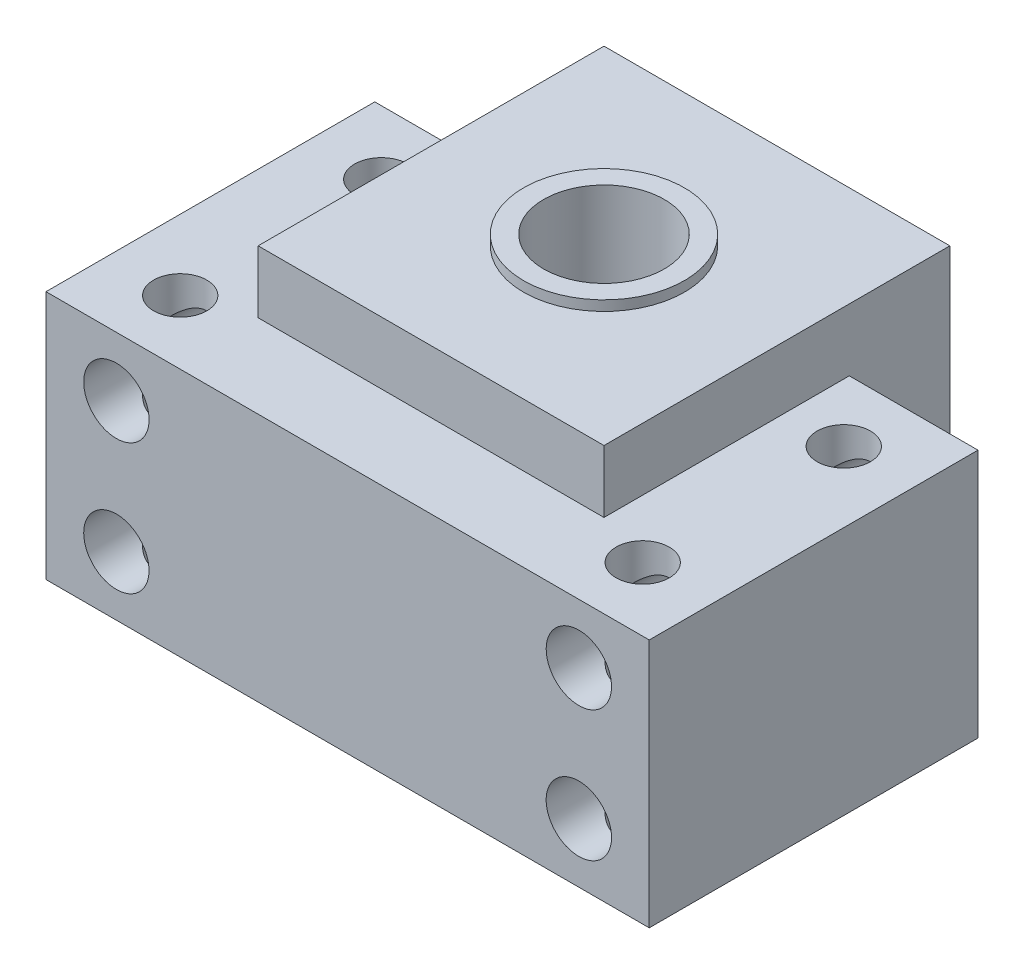
from build123d import *

# Parameters (mm, degrees)
SKETCH1_R           = 6
BOSS_EXTRUDE1_DEPTH = 24.8
SKETCH1_3_W         = 34.4
SKETCH1_3_H         = 34.4
SKETCH1_3_R         = 6
BOSS_EXTRUDE2_DEPTH = 31
SKETCH3_R           = 3.25
CUT_EXTRUDE1_DEPTH  = 61.698352531
SKETCH4_R           = 2.65
CUT_EXTRUDE2_DEPTH  = 51.112373721
SKETCH5_R           = 8
SKETCH5_R_2         = 6
BOSS_EXTRUDE3_DEPTH = 1


with BuildPart() as part:
    # Sketch1 → Boss-Extrude1 (new body)
    with BuildSketch(Plane(origin=(0, 0, 0), x_dir=(1, 0, 0), z_dir=(0, 1, 0))):
        Polygon((-30, 7.2), (-30, -25.5), (30, -25.5), (30, 7.2), (17.2, 7.2), (17.2, 17.2), (-17.2, 17.2), (-17.2, 7.2), align=None)
        Circle(SKETCH1_R, mode=Mode.SUBTRACT)
    extrude(amount=BOSS_EXTRUDE1_DEPTH)

    # Sketch1_3 → Boss-Extrude2 (add)
    with BuildSketch(Plane(origin=(0, 0, 0), x_dir=(1, 0, 0), z_dir=(0, 1, 0))):
        Rectangle(SKETCH1_3_W, SKETCH1_3_H)
        Circle(SKETCH1_3_R, mode=Mode.SUBTRACT)
    extrude(amount=BOSS_EXTRUDE2_DEPTH)

    # Sketch3 → Cut-Extrude1 (cut, through all)
    with BuildSketch(Plane.XY.offset(25.5)):
        with Locations((-23, 18.9)):
            Circle(SKETCH3_R)
        with Locations((-23, 5.9)):
            Circle(SKETCH3_R)
        with Locations((23, 5.9)):
            Circle(SKETCH3_R)
        with Locations((23, 18.9)):
            Circle(SKETCH3_R)
    extrude(amount=-CUT_EXTRUDE1_DEPTH, mode=Mode.SUBTRACT)

    # Sketch4 → Cut-Extrude2 (cut, through all)
    with BuildSketch(Plane.XZ):
        with Locations((-23, 19.15)):
            Circle(SKETCH4_R)
        with Locations((-23, -0.85)):
            Circle(SKETCH4_R)
        with Locations((23, -0.85)):
            Circle(SKETCH4_R)
        with Locations((23, 19.15)):
            Circle(SKETCH4_R)
    extrude(amount=-CUT_EXTRUDE2_DEPTH, mode=Mode.SUBTRACT)

    # Sketch5 → Boss-Extrude3 (add)
    with BuildSketch(Plane(origin=(0, 31, 0), x_dir=(1, 0, 0), z_dir=(0, 1, 0))):
        Circle(SKETCH5_R)
        Circle(SKETCH5_R_2, mode=Mode.SUBTRACT)
    extrude(amount=BOSS_EXTRUDE3_DEPTH)


solid = part.part
